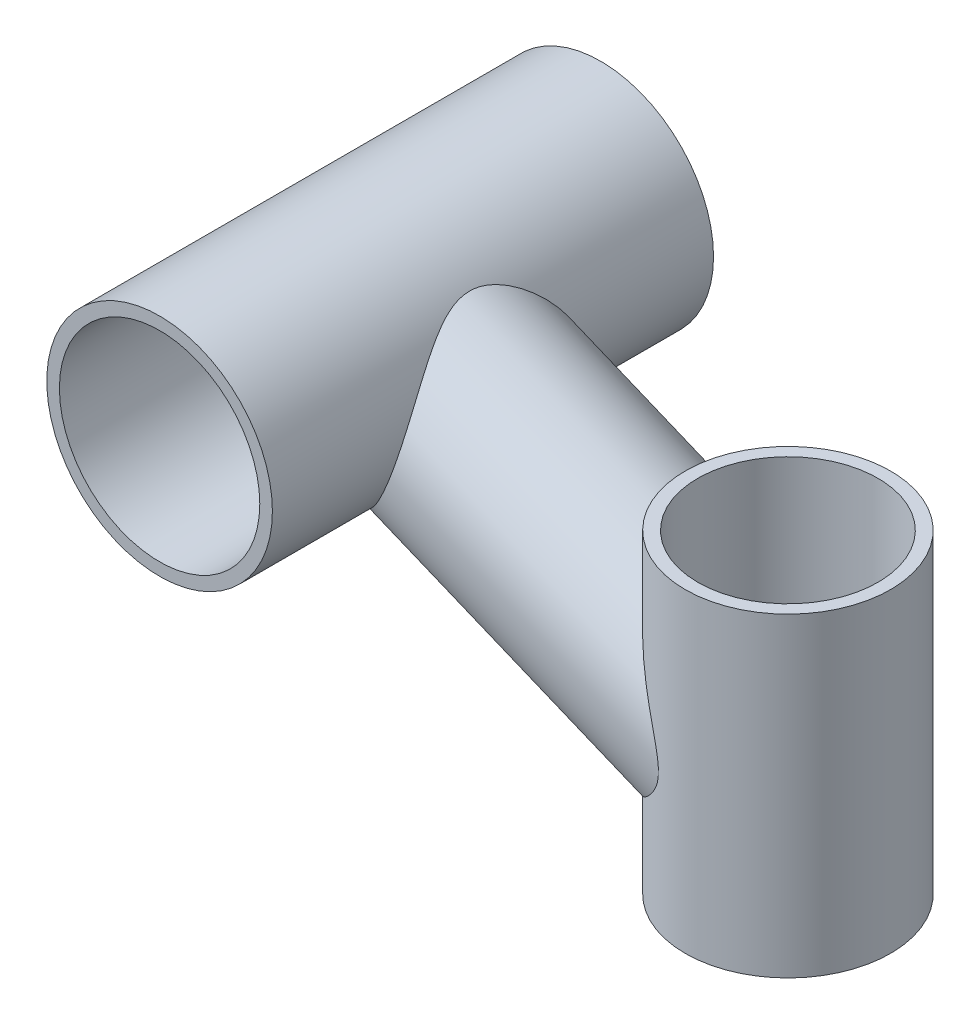
from build123d import *

# Parameters (mm, degrees)
ESQUISSE1_R                         = 17.9
ESQUISSE1_R_2                       = 15.9
ESQUISSE5_R                         = 16.3
ESQUISSE5_R_2                       = 14.3
BOSS_EXTRU_1_DEPTH                  = 30
BOSS_EXTRU_1_DEPTH_BACK             = 20
BOSS_EXTRU_2_REACH                  = 71.734
BOSS_EXTRU_2_END_RADIUS             = 16.3
ESQUISSE8_R                         = 15.5
ESQUISSE8_R_2                       = 12.5
BOSS_EXTRU_2_DIRECTION_2_REACH      = 71.734
BOSS_EXTRU_2_DIRECTION_2_END_RADIUS = 17.9


with BuildPart() as part:
    # Balayage1: sweep along a path in Esquisse2
    with BuildLine(Plane(origin=(0, 0, 0), x_dir=(0, 0, -1), z_dir=(1, 0, 0))) as balayage1_path:
        Line((-35, 0), (35, 0))
    # Esquisse1 → Balayage1 (sweep)
    with BuildSketch(Plane.XY):
        Circle(ESQUISSE1_R)
        Circle(ESQUISSE1_R_2, mode=Mode.SUBTRACT)
    sweep(path=balayage1_path.line)



with BuildPart() as body_2:
    # Esquisse5 → Boss.-Extru.1 (new, two sides)
    with BuildSketch(Plane(origin=(0, -26.71342567, 0), x_dir=(1, 0, 0), z_dir=(0, 1, 0))) as boss_extru_1_sk:
        with Locations(Location((64.702340676, 0, 0), (0, 0, 270))):
            Circle(ESQUISSE5_R)
        with Locations(Location((64.702340676, 0, 0), (0, 0, 270))):
            Circle(ESQUISSE5_R_2, mode=Mode.SUBTRACT)
    extrude(amount=BOSS_EXTRU_1_DEPTH)
    extrude(boss_extru_1_sk.sketch, amount=-BOSS_EXTRU_1_DEPTH_BACK)


with BuildPart() as part_1:
    add(part.part)

    add(body_2.part)  # Boss.-Extru.2 merges body 2
    # Boss.-Extru.2: up to this cylinder (the profile starts outside it)
    boss_extru_2_end = Plane(origin=(64.702340676, -27.278432, 0), z_dir=(0, 1, 0)) * Cylinder(BOSS_EXTRU_2_END_RADIUS, 177.068, mode=Mode.PRIVATE)
    # Esquisse8 → Boss.-Extru.2 (add, up to the surface)
    with BuildSketch(Plane(origin=(32.351170338, -13.356712835, 0), x_dir=(0, 0, -1), z_dir=(0.9243191525163077, -0.381620366714795, 0)), mode=Mode.PRIVATE) as boss_extru_2_sk1:
        with Locations(Location((0, 0, 0), (0, 0, 90))):
            Circle(ESQUISSE8_R)
        with Locations(Location((0, 0, 0), (0, 0, 90))):
            Circle(ESQUISSE8_R_2, mode=Mode.SUBTRACT)
    boss_extru_2_tool1 = extrude(boss_extru_2_sk1.sketch, amount=BOSS_EXTRU_2_REACH, mode=Mode.PRIVATE) - boss_extru_2_end
    add(boss_extru_2_tool1.solids().sort_by_distance((26.603359, -27.278432, 0))[0])

    # Boss.-Extru.2 direction 2: up to this cylinder (the profile starts outside it)
    boss_extru_2_direction_2_end = Plane(origin=(0, 0, 0), z_dir=(0, 0, 1)) * Cylinder(BOSS_EXTRU_2_DIRECTION_2_END_RADIUS, 180.268, mode=Mode.PRIVATE)
    # Esquisse8 → Boss.-Extru.2 direction 2 (add, up to the surface)
    with BuildSketch(Plane(origin=(32.351170338, -13.356712835, 0), x_dir=(0, 0, -1), z_dir=(0.9243191525163077, -0.381620366714795, 0)), mode=Mode.PRIVATE) as boss_extru_2_direction_2_sk1:
        with Locations(Location((0, 0, 0), (0, 0, 90))):
            Circle(ESQUISSE8_R)
        with Locations(Location((0, 0, 0), (0, 0, 90))):
            Circle(ESQUISSE8_R_2, mode=Mode.SUBTRACT)
    boss_extru_2_direction_2_tool1 = extrude(boss_extru_2_direction_2_sk1.sketch, amount=-BOSS_EXTRU_2_DIRECTION_2_REACH, mode=Mode.PRIVATE) - boss_extru_2_direction_2_end
    add(boss_extru_2_direction_2_tool1.solids().sort_by_distance((26.603359, -27.278432, 0))[0])


solid = part_1.part
